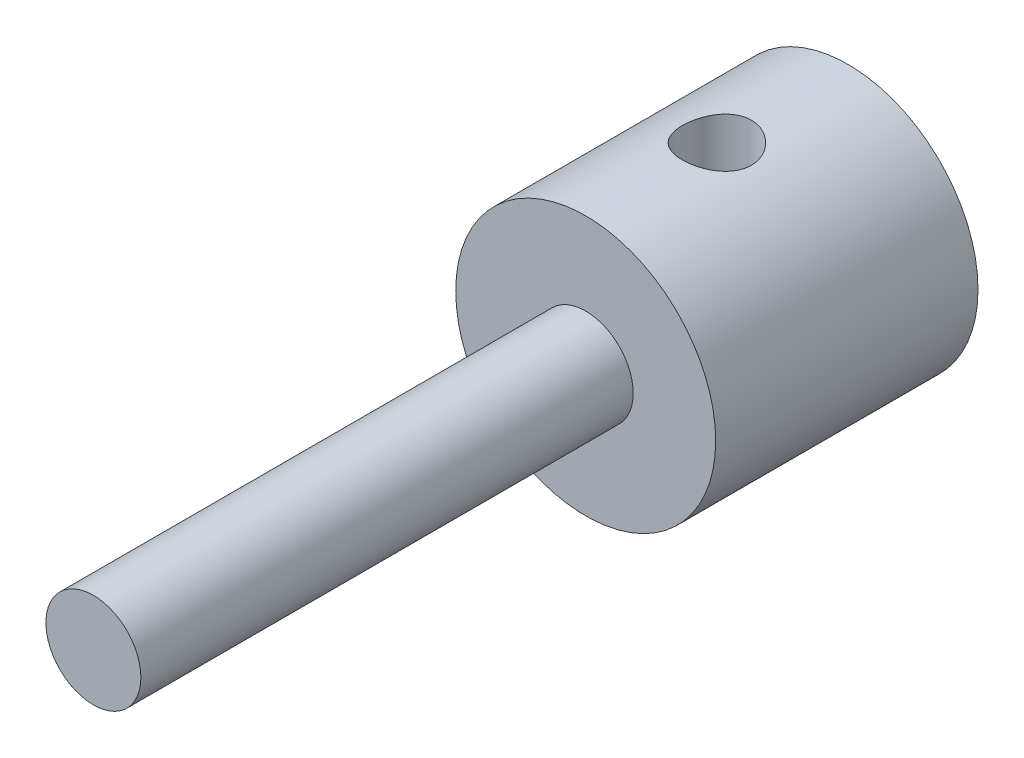
from build123d import *

# Parameters (mm, degrees)
SKETCH2_R           = 3.06197
BOSS_EXTRUDE1_DEPTH = 31.75
SKETCH3_R           = 8.382
BOSS_EXTRUDE2_DEPTH = 16.9164
SKETCH4_R           = 2.9972
CUT_EXTRUDE1_DEPTH  = 13.97
SKETCH5_R           = 2.2225
CUT_EXTRUDE2_DEPTH  = 13.97


with BuildPart() as part:
    # Sketch2 → Boss-Extrude1 (new body)
    with BuildSketch(Plane.XY):
        Circle(SKETCH2_R)
    extrude(amount=BOSS_EXTRUDE1_DEPTH)

    # Sketch3 → Boss-Extrude2 (add)
    with BuildSketch(Plane(origin=(0, 0, 0), x_dir=(-1, 0, 0), z_dir=(0, 0, -1))):
        Circle(SKETCH3_R)
    extrude(amount=BOSS_EXTRUDE2_DEPTH)

    # Sketch4 → Cut-Extrude1 (cut)
    with BuildSketch(Plane(origin=(0, 0, -16.9164), x_dir=(-1, 0, 0), z_dir=(0, 0, -1))):
        Circle(SKETCH4_R)
    extrude(amount=-CUT_EXTRUDE1_DEPTH, mode=Mode.SUBTRACT)

    # Sketch5 → Cut-Extrude2 (cut)
    with BuildSketch(Plane(origin=(0, 0, 0), x_dir=(1, 0, 0), z_dir=(0, 1, 0))):
        with Locations((0, 8.4582)):
            Circle(SKETCH5_R)
    extrude(amount=CUT_EXTRUDE2_DEPTH, mode=Mode.SUBTRACT)


solid = part.part
